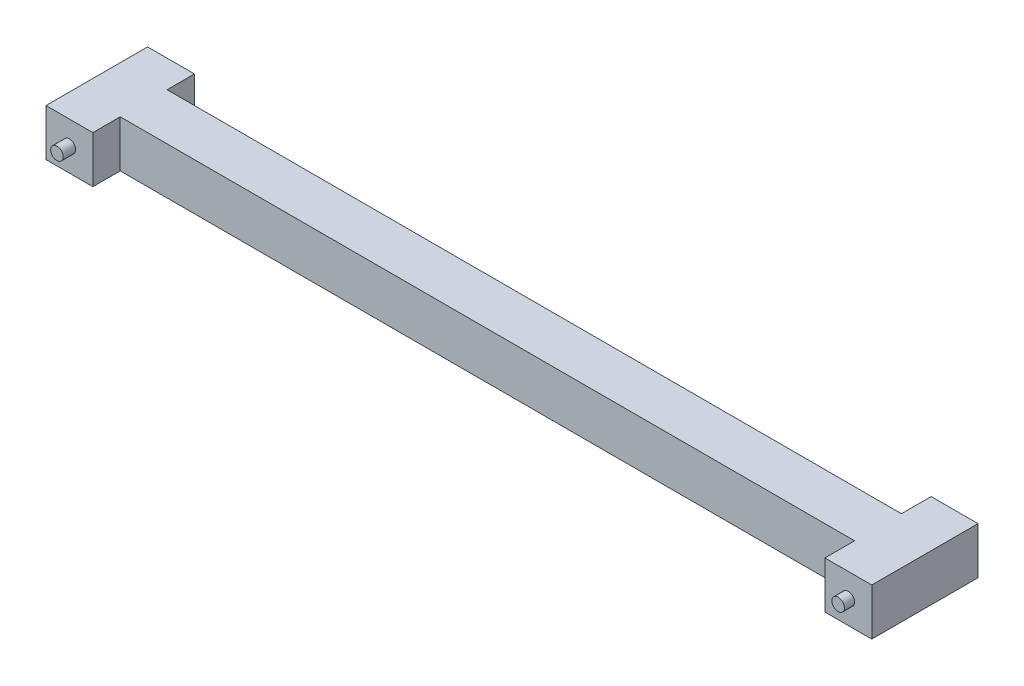
from build123d import *

# Parameters (mm, degrees)
SKETCH_1_W      = 6
SKETCH_1_H      = 6
EXTRUDE_1_DEPTH = 13
SKETCH_3_R      = 0.8
EXTRUDE_3_DEPTH = 1.6
SKETCH_4_W      = 6
SKETCH_4_H      = 3
EXTRUDE_4_DEPTH = 94
SKETCH_5_W      = 13.6
SKETCH_5_H      = 6
EXTRUDE_5_DEPTH = 6
SKETCH_2_R      = 0.8
EXTRUDE_2_DEPTH = 1.6
SKETCH_7_R      = 0.8
EXTRUDE_6_DEPTH = 1.6


with BuildPart() as part:
    # 草图1 → 凸台-拉伸1 (new body)
    with BuildSketch(Plane.XY):
        with Locations((-1.59089175, -3.42724845)):
            Rectangle(SKETCH_1_W, SKETCH_1_H)
    extrude(amount=EXTRUDE_1_DEPTH)

    # 草图3 → 凸台-拉伸3 (add)
    with BuildSketch(Plane(origin=(0, 0, 0), x_dir=(-1, 0, 0), z_dir=(0, 0, -1))):
        with Locations((1.59089175, -3.42724845)):
            Circle(SKETCH_3_R)
    extrude(amount=EXTRUDE_3_DEPTH)

    # 草图4 → 凸台-拉伸4 (add)
    with BuildSketch(Plane(origin=(1.40910825, 0, 0), x_dir=(0, 0, -1), z_dir=(1, 0, 0))):
        with Locations((-6.5, -4.92724845)):
            Rectangle(SKETCH_4_W, SKETCH_4_H)
        with Locations((-6.5, -1.92724845)):
            Rectangle(SKETCH_4_W, SKETCH_4_H)
    extrude(amount=EXTRUDE_4_DEPTH)

    # 草图5 → 凸台-拉伸5 (add)
    with BuildSketch(Plane(origin=(95.40910825, 0, 0), x_dir=(0, 0, -1), z_dir=(1, 0, 0))):
        with Locations((-6.5, -3.42724845)):
            Rectangle(SKETCH_5_W, SKETCH_5_H)
    extrude(amount=EXTRUDE_5_DEPTH)

    # 草图2 → 凸台-拉伸2 (add)
    with BuildSketch(Plane.XY.offset(13)):
        with Locations((-1.59089175, -3.42724845)):
            Circle(SKETCH_2_R)
        with Locations((98.40910825, -3.42724845)):
            Circle(SKETCH_2_R)
    extrude(amount=EXTRUDE_2_DEPTH)

    # 草图7 → 凸台-拉伸6 (add)
    with BuildSketch(Plane(origin=(0, 0, -0.3), x_dir=(-1, 0, 0), z_dir=(0, 0, -1))):
        with Locations((-98.40910825, -3.42724845)):
            Circle(SKETCH_7_R)
    extrude(amount=EXTRUDE_6_DEPTH)


solid = part.part
